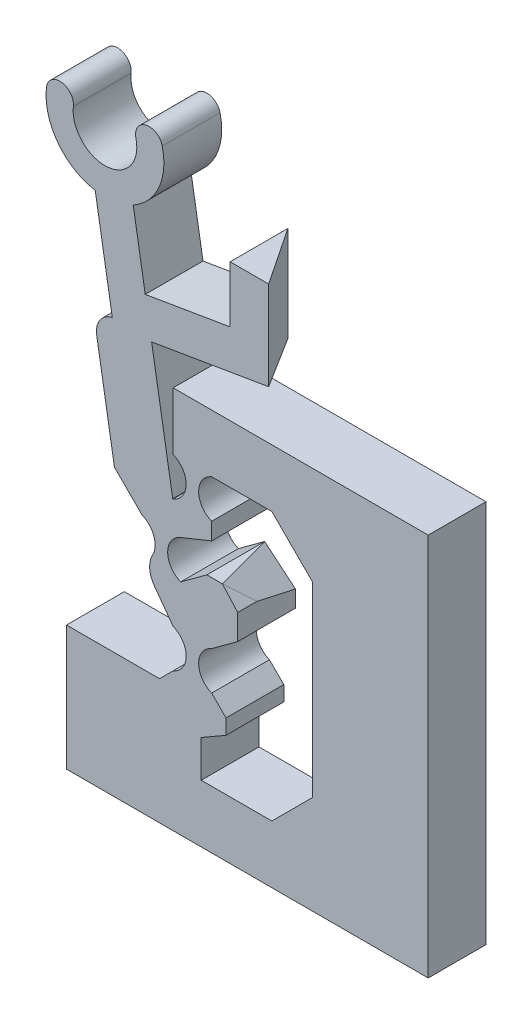
from build123d import *

# Parameters (mm, degrees)
BOSS_SWITCHMAIN_DEPTH           = 3
SKETCH1_W                       = 6.582729781
SKETCH1_H                       = 1.5
SKETCH1_W_2                     = 4.49100728
BOSS_FLANGE_WIDTH_DEPTH         = 6
SKETCH2_W                       = 5
SKETCH2_H                       = 1.490135464
SKETCH2_H_2                     = 1.5
SKETCH2_H_3                     = 2.286069733
BOSS_FLANGE_HEIGHT_DEPTH        = 11.6675
TAP_DRILL_FOR_M2X0_4_TAP1_D     = 1.6
M2_CLEARANCE_HOLE2_D            = 2.4
M2_CLEARANCE_HOLE2_DEPTH        = 6.484923868
M2_CLEARANCE_HOLE2_TIP          = 0.721032743
CUT_FLANGE_RAMP_CLEARANCE_REACH = 21.921
SKETCH10_W                      = 1.51157113
SKETCH10_H                      = 3
CUT_EXTRUDE1_REACH              = 29.069
CUT_EXTRUDE2_REACH              = 24.401
SKETCH14_W                      = 3.00210875
SKETCH14_H                      = 3.681985306
SKETCH15_W                      = 18.424052467
SKETCH15_H                      = 20.375612782
CUT_EXTRUDE3_DEPTH              = 7


with BuildPart() as part:
    # Sketch-SwitchBossUp → Boss-SwitchMain (new body)
    with BuildSketch(Plane.XY):
        with BuildLine():
            Line((6.540476927, 22.165014537), (6.540476927, 25.093856925))
            Line((6.540476927, 25.093856925), (8.540476927, 25.093856925))
            Line((8.540476927, 25.093856925), (8.540476927, 20.473554675))
            Line((8.540476927, 20.473554675), (2.463355023, 19.450530066))
            Line((2.463355023, 19.450530066), (3.558499615, 12.944990388))
            Line((3.558499615, 12.944990388), (3.581088316, 12.944953207))
            ThreePointArc((3.581088316, 12.944953207), (4.256080915, 13.944958203), (3.581073513, 14.944953207))
            Line((3.581073513, 14.944953207), (3.581073513, 17.94496801))
            Line((3.581073513, 17.94496801), (6.811292922, 17.94496801))
            Line((6.811292922, 17.94496801), (16.828083018, 17.94496801))
            Line((16.828083018, 17.94496801), (16.828083018, -1.975613284))
            Line((16.828083018, -1.975613284), (5.040476927, -1.975613284))
            Line((5.040476927, -1.975613284), (-1.954752854, -1.975613284))
            Line((-1.954752854, -1.975613284), (-1.954752854, 4.509310584))
            Line((-1.954752854, 4.509310584), (2.874043973, 4.509310584))
            Line((2.874043973, 4.509310584), (3.58114552, 5.216422599))
            ThreePointArc((3.58114552, 5.216422599), (4.256138119, 6.216427595), (3.581130717, 7.216422599))
            Line((3.581130717, 7.216422599), (2.603418204, 8.548280984))
            ThreePointArc((2.603418204, 8.548280984), (2.363042898, 9.20714873), (2.514052348, 9.892045174))
            ThreePointArc((2.514052348, 9.892045174), (2.58326881, 10.772563057), (1.97126394, 11.409393254))
            Line((1.97126394, 11.409393254), (0.5326123, 12.848023597))
            Line((0.5326123, 12.848023597), (-0.388805291, 18.321564484))
            ThreePointArc((-0.388805291, 18.321564484), (-0.224136417, 19.087558912), (0.421628056, 19.531238467))
            Line((0.421628056, 19.531238467), (-0.465233701, 24.799505683))
            ThreePointArc((-0.465233701, 24.799505683), (-2.406587703, 25.978955839), (-3.001107523, 28.171329943))
            ThreePointArc((-3.001107523, 28.171329943), (-2.220760115, 28.789797628), (-1.602292431, 28.009450221))
            ThreePointArc((-1.602292431, 28.009450221), (0.141134159, 26.168671513), (1.647974165, 28.207650602))
            ThreePointArc((1.647974165, 28.207650602), (2.167041147, 29.057364566), (3.016755111, 28.538297585))
            ThreePointArc((3.016755111, 28.538297585), (2.839798095, 26.578800421), (1.507016259, 25.131514861))
            Line((1.507016259, 25.131514861), (2.131345845, 21.422780026))
            Line((2.131345845, 21.422780026), (6.540476927, 22.165014537))
        make_face()
        with BuildLine():
            Line((5.581088316, 12.94496801), (5.581094877, 12.05857133))
            Line((5.581094877, 12.05857133), (3.97126394, 11.409408058))
            ThreePointArc((3.97126394, 11.409408058), (3.296271341, 10.409403061), (3.971278743, 9.409408058))
            Line((3.971278743, 9.409408058), (5.332971639, 10.409021979))
            Line((5.332971639, 10.409021979), (6.133921896, 10.409027907))
            Line((6.133921896, 10.409027907), (6.935397893, 9.518898634))
            Line((6.935397893, 9.518898634), (6.935397893, 8.210600129))
            Line((6.935397893, 8.210600129), (5.581130717, 7.216437402))
            ThreePointArc((5.581130717, 7.216437402), (4.906138119, 6.216432406), (5.58114552, 5.216437402))
            Line((5.58114552, 5.216437402), (6.327120808, 4.470473157))
            Line((6.327120808, 4.470473157), (6.327120808, 3.690267188))
            Line((6.327120808, 3.690267188), (5.040476927, 2.947422997))
            Line((5.040476927, 2.947422997), (5.040476927, 1.024386716))
            Line((5.040476927, 1.024386716), (8.706762674, 1.024386716))
            Line((8.706762674, 1.024386716), (10.828083018, 3.145707059))
            Line((10.828083018, 3.145707059), (10.828083018, 12.823647666))
            Line((10.828083018, 12.823647666), (8.706762674, 14.94496801))
            Line((8.706762674, 14.94496801), (6.811292922, 14.94496801))
            Line((6.811292922, 14.94496801), (5.581073513, 14.94496801))
            ThreePointArc((5.581073513, 14.94496801), (4.906080915, 13.944963014), (5.581088316, 12.94496801))
        make_face(mode=Mode.SUBTRACT)
    extrude(amount=BOSS_SWITCHMAIN_DEPTH)

    # Sketch1 → Boss-Flange Width (add)
    with BuildSketch(Plane(origin=(0, 0, 0), x_dir=(-1, 0, 0), z_dir=(0, 0, -1))):
        with Locations((-1.336612037, -0.439543551)):
            Rectangle(SKETCH1_W, SKETCH1_H)
        Polygon((-3.581073513, 17.94496801), (-6.639548057, 17.94496801), (-6.811292922, 16.454832546), (-3.581073513, 16.454832546), align=None)
        with Locations((-0.290750786, 3.759310584)):
            Rectangle(SKETCH1_W_2, SKETCH1_H)
    extrude(amount=BOSS_FLANGE_WIDTH_DEPTH)

    # Sketch2 → Boss-Flange Height (add)
    with BuildSketch(Plane(origin=(-7.039523073, 0, 0), x_dir=(0, 0, -1), z_dir=(1, 0, 0))):
        with Locations((3.5, 17.199900278)):
            Rectangle(SKETCH2_W, SKETCH2_H)
        with Locations((3.5, 3.759310584)):
            Rectangle(SKETCH2_W, SKETCH2_H_2)
        with Locations((3.5, -0.832578417)):
            Rectangle(SKETCH2_W, SKETCH2_H_3)
    extrude(amount=BOSS_FLANGE_HEIGHT_DEPTH)

    # Tap Drill for M2x0.4 Tap1 (through all)
    with Locations(Plane(origin=(0, -1.975613284, 0), x_dir=(-1, 0, 0), z_dir=(0, -1, 0))):
        with Locations((4.039523073, 3.5), (-1.627976927, 3.5)):
            Hole(TAP_DRILL_FOR_M2X0_4_TAP1_D / 2)

    # M2 Clearance Hole2
    with Locations(Plane.XZ.offset(1.975613284)):
        with Locations((-4.039523073, -3.5), (1.627976927, -3.5)):
            Hole(M2_CLEARANCE_HOLE2_D / 2, depth=M2_CLEARANCE_HOLE2_DEPTH)
            with Locations((0, 0, -(M2_CLEARANCE_HOLE2_DEPTH + M2_CLEARANCE_HOLE2_TIP / 2))):  # 118° drill point
                Cone(0, M2_CLEARANCE_HOLE2_D / 2, M2_CLEARANCE_HOLE2_TIP, mode=Mode.SUBTRACT)

    # Sketch10 → Cut-Flange Ramp Clearance (cut, up to next)
    with BuildSketch(Plane(origin=(0, 17.94496801, 0), x_dir=(1, 0, 0), z_dir=(0, 1, 0)), mode=Mode.PRIVATE) as cut_flange_ramp_clearance_sk1:
        with Locations((5.883762492, 4.5)):
            Rectangle(SKETCH10_W, SKETCH10_H)
    cut_flange_ramp_clearance_tool1 = extrude(cut_flange_ramp_clearance_sk1.sketch, amount=-CUT_FLANGE_RAMP_CLEARANCE_REACH, mode=Mode.PRIVATE) & part.part
    add(cut_flange_ramp_clearance_tool1.solids().sort_by_distance((5.883762, 17.944968, -4.5))[0], mode=Mode.SUBTRACT)

    # Sketch12 → Cut-Extrude1 (cut, up to next)
    with BuildSketch(Plane(origin=(0, 25.093856925, 0), x_dir=(1, 0, 0), z_dir=(0, 1, 0)), mode=Mode.PRIVATE) as cut_extrude1_sk1:
        Polygon((6.540476927, 0), (8.540476927, -3), (8.540476927, 0), align=None)
    cut_extrude1_tool1 = extrude(cut_extrude1_sk1.sketch, amount=-CUT_EXTRUDE1_REACH, mode=Mode.PRIVATE) & part.part
    add(cut_extrude1_tool1.solids().sort_by_distance((7.87381, 25.093857, 1))[0], mode=Mode.SUBTRACT)

    # Sketch14 → Cut-Extrude2 (cut, up to next)
    with BuildSketch(Plane(origin=(7.097281825, 8.517301779, -1.894873399), x_dir=(-0.775775184, 0.615950427, -0.137032608), z_dir=(-0.631009401, -0.757261389, 0.168470544)), mode=Mode.PRIVATE) as cut_extrude2_sk1:
        with Locations((1.064245886, -3.532126158)):
            Rectangle(SKETCH14_W, SKETCH14_H)
    cut_extrude2_tool1 = extrude(cut_extrude2_sk1.sketch, amount=-CUT_EXTRUDE2_REACH, mode=Mode.PRIVATE) & part.part
    add(cut_extrude2_tool1.solids().sort_by_distance((6.271666, 9.939876, 1.407123))[0], mode=Mode.SUBTRACT)

    # Sketch15 → Cut-Extrude3 (cut, through all)
    with BuildSketch(Plane(origin=(0, 0, 0), x_dir=(-1, 0, 0), z_dir=(0, 0, -1))):
        with Locations((-0.841389079, 8.027902003)):
            Rectangle(SKETCH15_W, SKETCH15_H)
    extrude(amount=CUT_EXTRUDE3_DEPTH, mode=Mode.SUBTRACT)


solid = part.part
